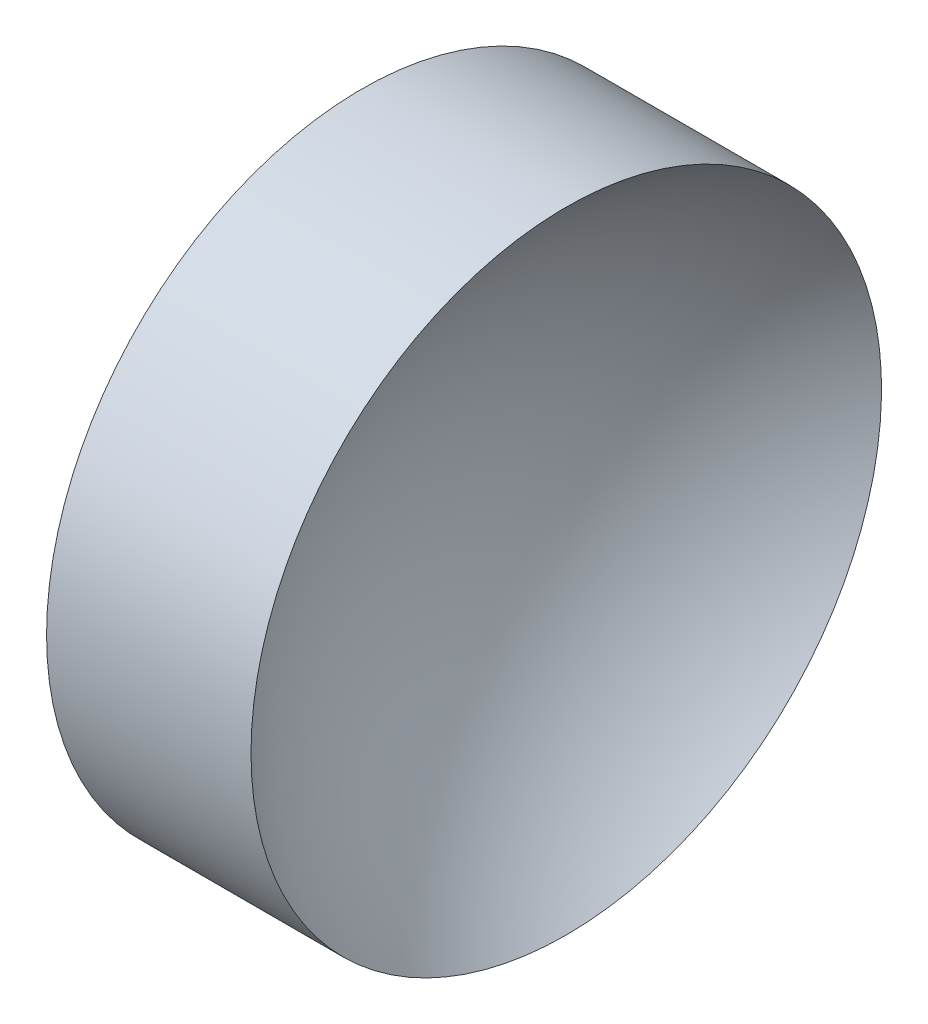
from build123d import *


with BuildPart() as part:
    # 草图1 → 旋转1 (revolve)
    with BuildSketch(Plane.XY, mode=Mode.PRIVATE) as revolve_1_sk:
        with BuildLine():
            Line((119.362930792, 71.193989087), (119.362930792, 83.893989087))
            Line((119.362930792, 83.893989087), (127.599037579, 83.893989087))
            ThreePointArc((127.599037579, 83.893989087), (123.006066351, 78.268220986), (121.362930792, 71.193989087))
            Line((121.362930792, 71.193989087), (119.362930792, 71.193989087))
        make_face()
    revolve(revolve_1_sk.sketch.rotate(Axis((111.955229758, 71.193989087, 0), (1, 0, 0)), 180), axis=Axis((111.955229758, 71.193989087, 0), (1, 0, 0)))  # turned: the seam where the file's is


solid = part.part
